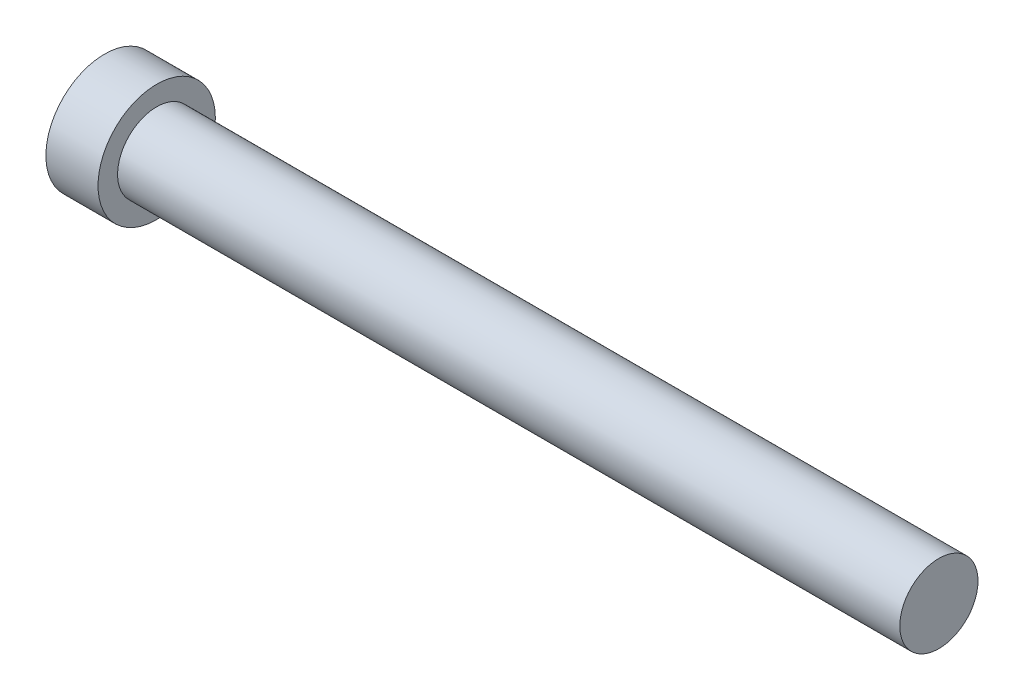
from build123d import *

# Parameters (mm, degrees)
SKETCH1_R           = 2.25
BOSS_EXTRUDE1_DEPTH = 2
SKETCH2_R           = 1.5
BOSS_EXTRUDE2_DEPTH = 30


with BuildPart() as part:
    # Sketch1 → Boss-Extrude1 (new body)
    with BuildSketch(Plane(origin=(0, 0, 0), x_dir=(0, 0, -1), z_dir=(1, 0, 0))):
        Circle(SKETCH1_R)
    extrude(amount=BOSS_EXTRUDE1_DEPTH)

    # Sketch2 → Boss-Extrude2 (add)
    with BuildSketch(Plane(origin=(2, 0, 0), x_dir=(0, 0, -1), z_dir=(1, 0, 0))):
        Circle(SKETCH2_R)
    extrude(amount=BOSS_EXTRUDE2_DEPTH)


solid = part.part
